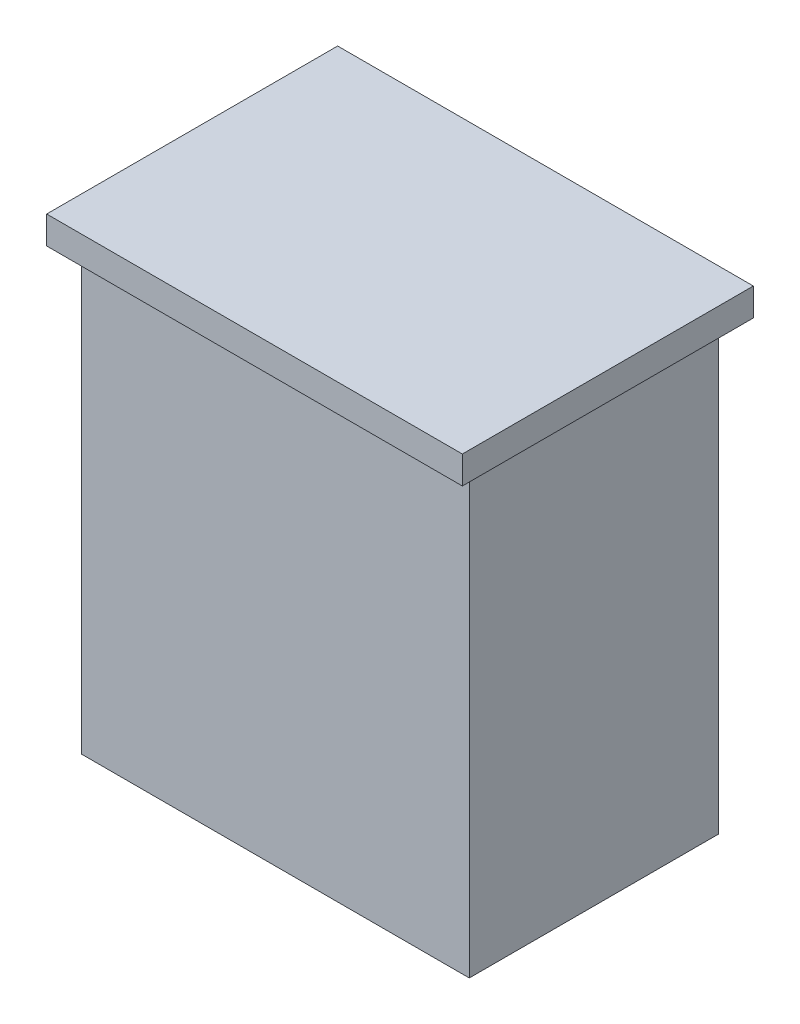
from build123d import *

# Parameters (mm, degrees)
SKETCH_1_W      = 14
SKETCH_1_H      = 9
EXTRUDE_1_DEPTH = 16
SKETCH_2_W      = 15
SKETCH_2_H      = 10.5
EXTRUDE_2_DEPTH = 1


with BuildPart() as part:
    # 草图1 → 凸台-拉伸1 (new body)
    with BuildSketch(Plane(origin=(0, 0, 0), x_dir=(1, 0, 0), z_dir=(0, 1, 0))):
        Rectangle(SKETCH_1_W, SKETCH_1_H)
    extrude(amount=EXTRUDE_1_DEPTH)

    # 草图2 → 凸台-拉伸2 (add)
    with BuildSketch(Plane(origin=(0, 16, 0), x_dir=(1, 0, 0), z_dir=(0, 1, 0))):
        Rectangle(SKETCH_2_W, SKETCH_2_H)
    extrude(amount=EXTRUDE_2_DEPTH)


solid = part.part
